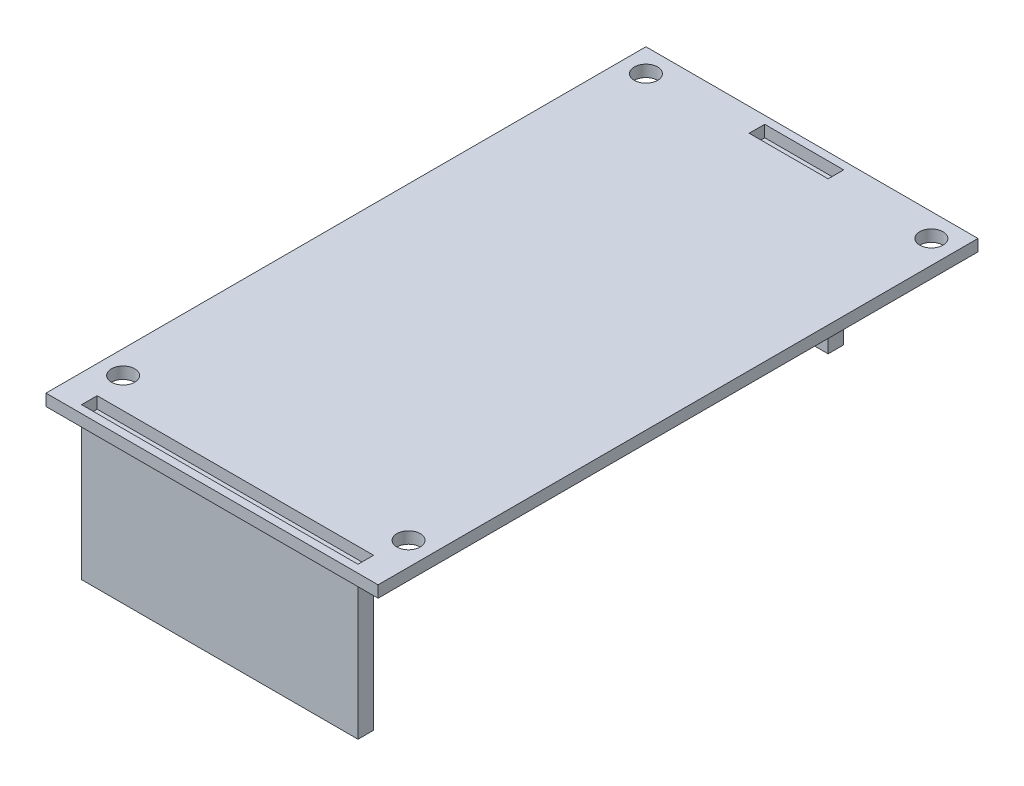
from build123d import *

# Parameters (mm, degrees)
SKETCH1_W           = 42.72
SKETCH1_H           = 77.18
SKETCH1_R           = 1.5
SKETCH1_W_2         = 35.56
SKETCH1_H_2         = 2
SKETCH1_W_3         = 10.16
BOSS_EXTRUDE1_DEPTH = 1.5
SKETCH2_W           = 35.56
SKETCH2_H           = 2
BOSS_EXTRUDE2_DEPTH = 18
SKETCH3_W           = 10.16
SKETCH3_H           = 2
BOSS_EXTRUDE3_DEPTH = 18


with BuildPart() as part:
    # Sketch1 → Boss-Extrude1 (new body)
    with BuildSketch(Plane(origin=(0, 0, 0), x_dir=(1, 0, 0), z_dir=(0, 1, 0))):
        with Locations((21.36, 38.59)):
            Rectangle(SKETCH1_W, SKETCH1_H)
        with Locations((39.72, 74.18)):
            Circle(SKETCH1_R, mode=Mode.SUBTRACT)
        with Locations((3, 74.18)):
            Circle(SKETCH1_R, mode=Mode.SUBTRACT)
        with Locations((3, 6.92)):
            Circle(SKETCH1_R, mode=Mode.SUBTRACT)
        with Locations((39.72, 6.92)):
            Circle(SKETCH1_R, mode=Mode.SUBTRACT)
        with Locations((21.36, 2)):
            Rectangle(SKETCH1_W_2, SKETCH1_H_2, mode=Mode.SUBTRACT)
        with Locations((21.36, 75.18)):
            Rectangle(SKETCH1_W_3, SKETCH1_H_2, mode=Mode.SUBTRACT)
    extrude(amount=BOSS_EXTRUDE1_DEPTH)


with BuildPart() as body_2:
    # Sketch2 → Boss-Extrude2 (new body)
    with BuildSketch(Plane.XZ):
        with Locations((21.36, -2)):
            Rectangle(SKETCH2_W, SKETCH2_H)
    extrude(amount=BOSS_EXTRUDE2_DEPTH)


with BuildPart() as body_3:
    # Sketch3 → Boss-Extrude3 (new body)
    with BuildSketch(Plane.XZ):
        with Locations((21.36, -75.18)):
            Rectangle(SKETCH3_W, SKETCH3_H)
    extrude(amount=BOSS_EXTRUDE3_DEPTH)


solid = Compound([part.part, body_2.part, body_3.part])
